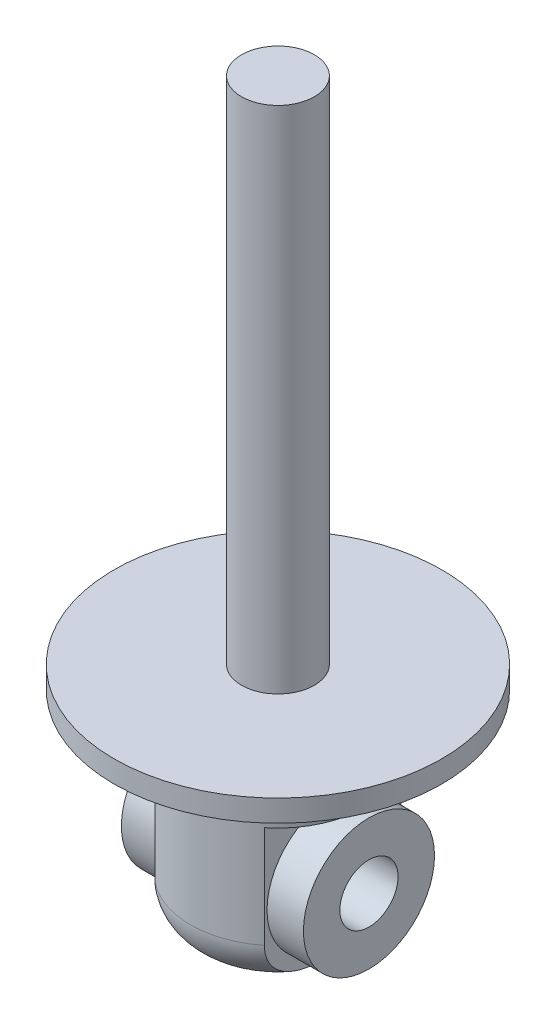
from build123d import *

# Parameters (mm, degrees)
SKETCH1_R           = 22.5
BOSS_EXTRUDE1_DEPTH = 3
SKETCH2_R           = 5
BOSS_EXTRUDE2_DEPTH = 70
SKETCH3_R           = 12
BOSS_EXTRUDE3_DEPTH = 28
FILLET1_R           = 6
SKETCH4_W           = 14.522746449
SKETCH4_H           = 20
CUT_EXTRUDE2_DEPTH  = 14
SKETCH5_R           = 4
CUT_EXTRUDE3_DEPTH  = 31
SKETCH7_R           = 9
SKETCH7_R_2         = 4
BOSS_EXTRUDE4_DEPTH = 12.5


with BuildPart() as part:
    # Sketch1 → Boss-Extrude1 (new body)
    with BuildSketch(Plane(origin=(0, 0, 0), x_dir=(1, 0, 0), z_dir=(0, 1, 0))):
        Circle(SKETCH1_R)
    extrude(amount=BOSS_EXTRUDE1_DEPTH)

    # Sketch2 → Boss-Extrude2 (add)
    with BuildSketch(Plane(origin=(0, 3, 0), x_dir=(1, 0, 0), z_dir=(0, 1, 0))):
        Circle(SKETCH2_R)
    extrude(amount=BOSS_EXTRUDE2_DEPTH)

    # Sketch3 → Boss-Extrude3 (add)
    with BuildSketch(Plane.XZ):
        Circle(SKETCH3_R)
    extrude(amount=BOSS_EXTRUDE3_DEPTH)

    # Fillet1
    fillet1_edges = [part.edges().sort_by_distance(p)[0] for p in [
        (-12, -28, 0),
    ]]
    fillet(fillet1_edges, radius=FILLET1_R)

    # Sketch4 → Cut-Extrude2 (cut, symmetric)
    with BuildSketch(Plane.XY):
        with Locations((-14.761373225, -18)):
            Rectangle(SKETCH4_W, SKETCH4_H)
        with Locations((14.761373225, -18)):
            Rectangle(SKETCH4_W, SKETCH4_H)
    extrude(amount=CUT_EXTRUDE2_DEPTH, both=True, mode=Mode.SUBTRACT)

    # Sketch5 → Cut-Extrude3 (cut, through all)
    with BuildSketch(Plane(origin=(7.5, 0, 0), x_dir=(0, 0, -1), z_dir=(1, 0, 0))):
        with Locations((0, -18)):
            Circle(SKETCH5_R)
    extrude(amount=-CUT_EXTRUDE3_DEPTH, mode=Mode.SUBTRACT)

    # Sketch7 → Boss-Extrude4 (add, symmetric)
    with BuildSketch(Plane(origin=(0, 0, 0), x_dir=(0, 0, -1), z_dir=(1, 0, 0))):
        with Locations((0, -18)):
            Circle(SKETCH7_R)
        with Locations((0, -18)):
            Circle(SKETCH7_R_2, mode=Mode.SUBTRACT)
    extrude(amount=BOSS_EXTRUDE4_DEPTH, both=True)


solid = part.part
